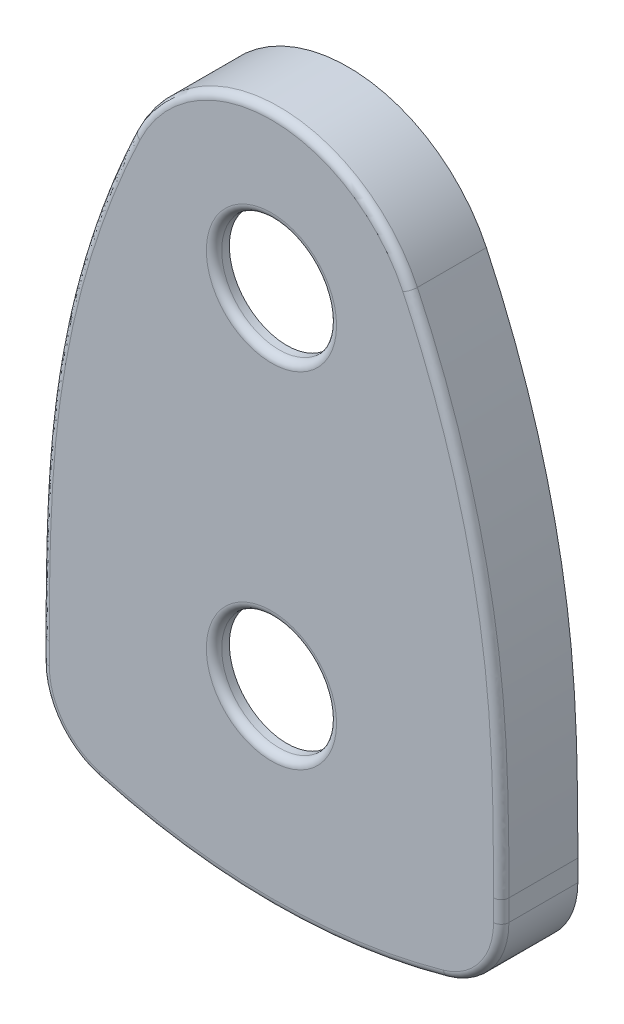
from build123d import *

# Parameters (mm, degrees)
EXTRUDE_1_DEPTH     = 10
FILLET_1_R          = 10
SHELL_1_T           = -2
SKETCH_2_R          = 7.5
CUT_EXTRUDE_1_DEPTH = 10
FILLET_2_R          = 1


with BuildPart() as part:
    # 草图1 → 凸台-拉伸1 (new body)
    with BuildSketch(Plane.XY):
        with BuildLine():
            add(Edge.make_bspline(
                [(-18.059479814, 8.593904168), (-23.948193256, -3.780809287), (-29.696472288, -24.34126392), (-30, -45.953108691), (-30, -54.460180984)],
                knots=[0, 0, 0, 0, 0.608662134, 1, 1, 1, 1], degree=3))
            Line((-30, -54.460180984), (-30, -64.460180984))
            ThreePointArc((-30, -64.460180984), (0, -70), (30, -64.460180984))
            Line((30, -64.460180984), (30, -54.460180984))
            add(Edge.make_bspline(
                [(18.059479814, 8.593904168), (23.423782854, -2.678798038), (29.865056496, -24.432184966), (30, -46.291744963), (30, -54.460180984)],
                knots=[0, 0, 0, 0, 0.608662134, 1, 1, 1, 1], degree=3))
            ThreePointArc((18.059479814, 8.593904168), (0, 20), (-18.059479814, 8.593904168))
        make_face()
    extrude(amount=EXTRUDE_1_DEPTH)

    # 圆角1
    fillet_1_edges = [part.edges().sort_by_distance(p)[0] for p in [
        (30, -64.460180984, 5),
        (-30, -64.460180984, 5),
    ]]
    fillet(fillet_1_edges, radius=FILLET_1_R)

    # 抽壳1
    shell_1_openings = [part.faces().sort_by_distance(p)[0] for p in [
        (0, -33.886417401, 0),
    ]]
    offset(amount=SHELL_1_T, openings=shell_1_openings, kind=Kind.INTERSECTION)

    # 草图2 → 切除-拉伸1 (cut)
    with BuildSketch(Plane.XY.offset(10)):
        Circle(SKETCH_2_R)
        with Locations((0, -45)):
            Circle(SKETCH_2_R)
    extrude(amount=-CUT_EXTRUDE_1_DEPTH, mode=Mode.SUBTRACT)

    # 圆角2
    fillet_2_edges = [part.edges().sort_by_distance(p)[0] for p in [
        (-30, -55.853116753, 10),
        (0, -70, 10),
        (30, -55.853116753, 10),
        (27.969536593, -63.286457019, 10),
        (-27.969536593, -63.286457019, 10),
        (-7.5, 0, 10),
        (-7.5, -45, 10),
        (0, 20, 10),
    ]]
    fillet(fillet_2_edges, radius=FILLET_2_R)


solid = part.part
